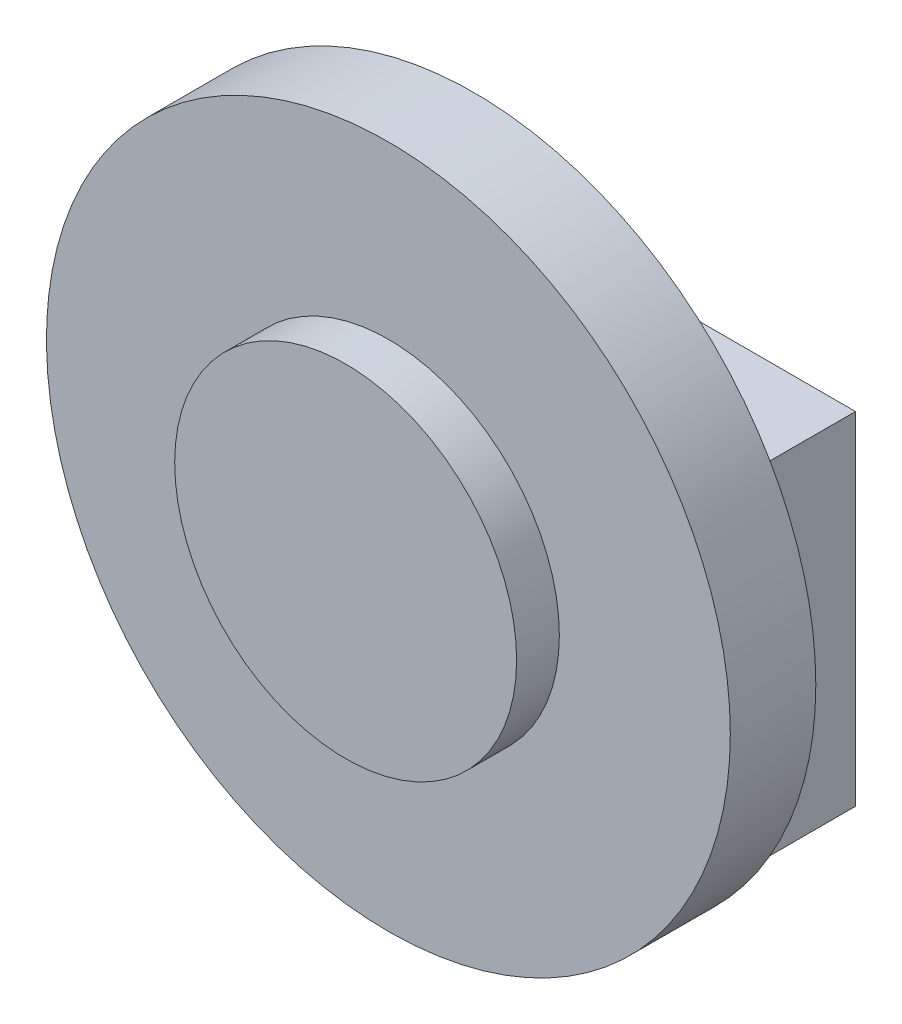
from build123d import *

# Parameters (mm, degrees)
ESBO_O1_R                = 4
RESSALTO_EXTRUS_O1_DEPTH = 1
ESBO_O2_R                = 2
RESSALTO_EXTRUS_O2_DEPTH = 0.5
ESBO_O3_W                = 6.92820323
ESBO_O3_H                = 4
RESSALTO_EXTRUS_O3_DEPTH = 1


with BuildPart() as part:
    # Esboço1 → Ressalto-extrusão1 (new body)
    with BuildSketch(Plane.XY):
        Circle(ESBO_O1_R)
    extrude(amount=RESSALTO_EXTRUS_O1_DEPTH)

    # Esboço2 → Ressalto-extrusão2 (add)
    with BuildSketch(Plane.XY.offset(1)):
        Circle(ESBO_O2_R)
    extrude(amount=RESSALTO_EXTRUS_O2_DEPTH)

    # Esboço3 → Ressalto-extrusão3 (add)
    with BuildSketch(Plane(origin=(0, 0, 0), x_dir=(-1, 0, 0), z_dir=(0, 0, -1))):
        Rectangle(ESBO_O3_W, ESBO_O3_H)
    extrude(amount=RESSALTO_EXTRUS_O3_DEPTH)


solid = part.part
